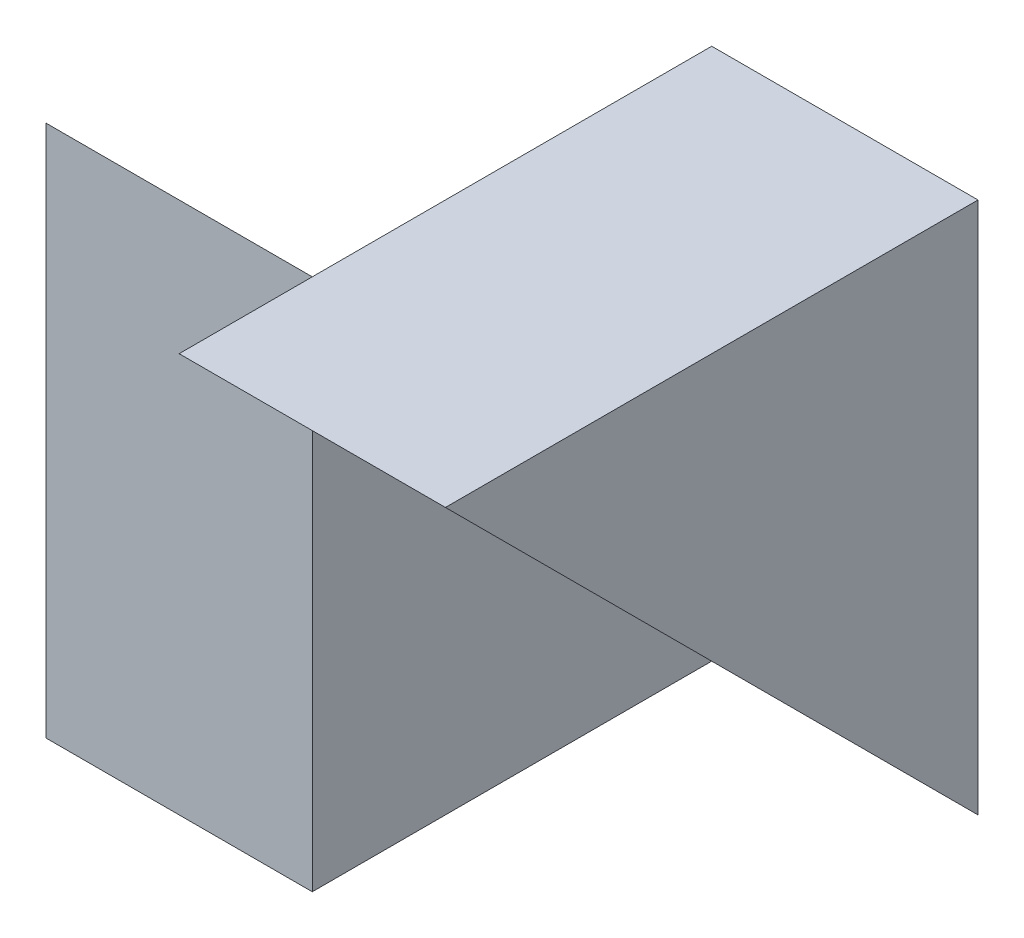
from build123d import *

# Parameters (mm, degrees)
SKETCH1_W           = 4
SKETCH1_H           = 4
BOSS_EXTRUDE1_DEPTH = 2
SKETCH2_W           = 3
SKETCH2_H           = 4
BOSS_EXTRUDE2_DEPTH = 2
CUT_EXTRUDE1_DEPTH  = 2
CUT_EXTRUDE2_DEPTH  = 2


with BuildPart() as part:
    # Sketch1 → Boss-Extrude1 (new body)
    with BuildSketch(Plane(origin=(0, 0, 0), x_dir=(0, 0, -1), z_dir=(1, 0, 0))):
        with Locations((2, 2)):
            Rectangle(SKETCH1_W, SKETCH1_H)
    extrude(amount=BOSS_EXTRUDE1_DEPTH)

    # Sketch2 → Boss-Extrude2 (add)
    with BuildSketch(Plane.ZY):
        with Locations((-2.5, 2)):
            Rectangle(SKETCH2_W, SKETCH2_H)
    extrude(amount=BOSS_EXTRUDE2_DEPTH)

    # Sketch3 → Cut-Extrude1 (cut)
    with BuildSketch(Plane.ZY.offset(2)):
        Polygon((-1, 4), (-4, 0), (-4, 4), align=None)
    extrude(amount=-CUT_EXTRUDE1_DEPTH, mode=Mode.SUBTRACT)

    # Sketch4 → Cut-Extrude2 (cut)
    with BuildSketch(Plane(origin=(2, 0, 0), x_dir=(0, 0, -1), z_dir=(1, 0, 0))):
        Polygon((4, 0), (0, 4), (0, 0), align=None)
    extrude(amount=-CUT_EXTRUDE2_DEPTH, mode=Mode.SUBTRACT)


solid = part.part
